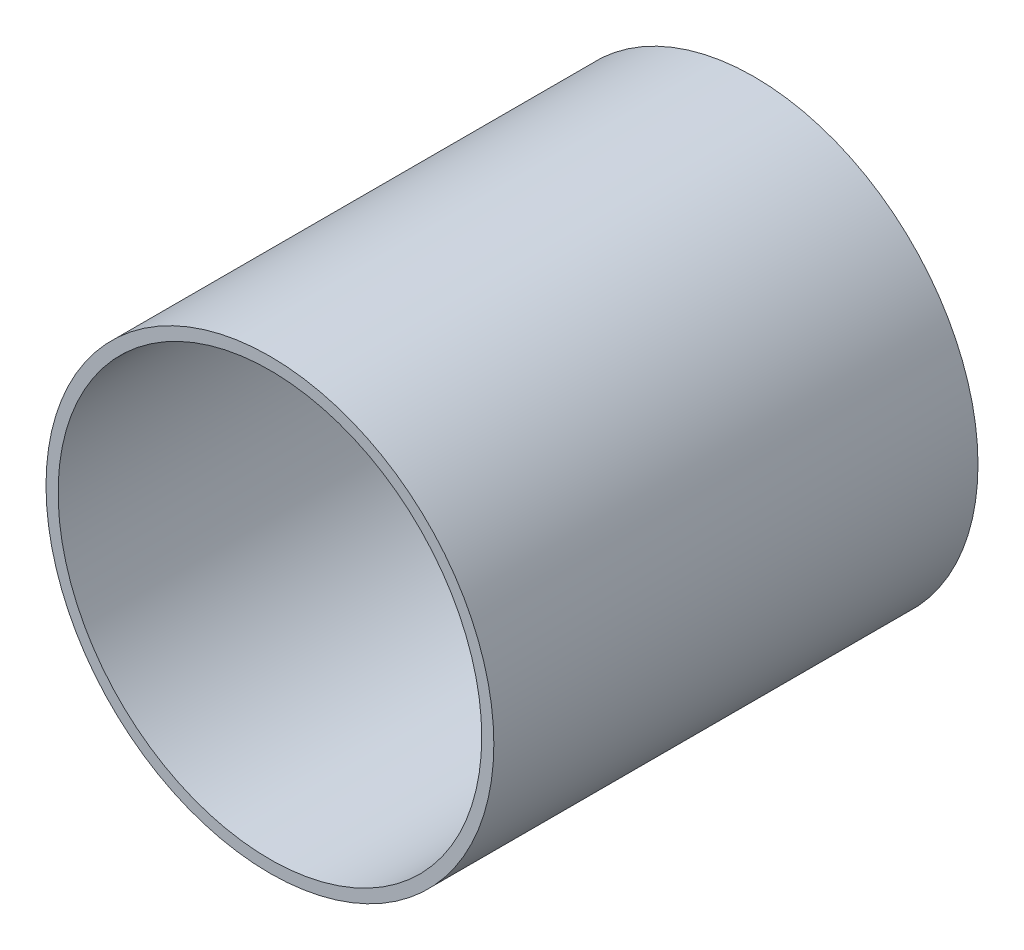
from build123d import *

# Parameters (mm, degrees)
SKETCH1_R           = 7.4
SKETCH1_R_2         = 7
EXTRUDE_THIN1_DEPTH = 16


with BuildPart() as part:
    # Sketch1 → Extrude-Thin1 (new body)
    with BuildSketch(Plane.XY):
        Circle(SKETCH1_R)
        Circle(SKETCH1_R_2, mode=Mode.SUBTRACT)
    extrude(amount=EXTRUDE_THIN1_DEPTH)


solid = part.part
